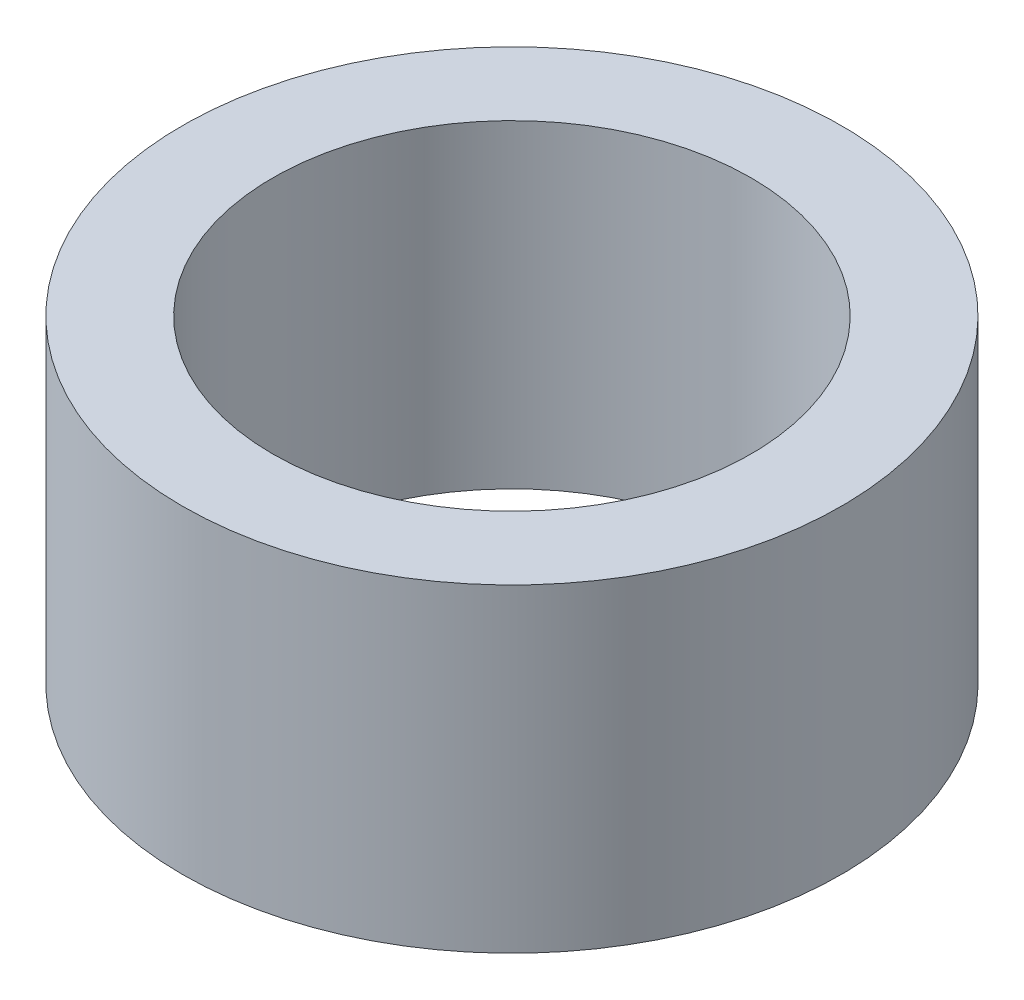
from build123d import *

# Parameters (mm, degrees)
SKETCH1_R           = 3.1
SKETCH1_R_2         = 2.25
BOSS_EXTRUDE1_DEPTH = 3


with BuildPart() as part:
    # Sketch1 → Boss-Extrude1 (new body)
    with BuildSketch(Plane(origin=(0, 0, 0), x_dir=(1, 0, 0), z_dir=(0, 1, 0))):
        Circle(SKETCH1_R)
        Circle(SKETCH1_R_2, mode=Mode.SUBTRACT)
    extrude(amount=BOSS_EXTRUDE1_DEPTH)


solid = part.part
